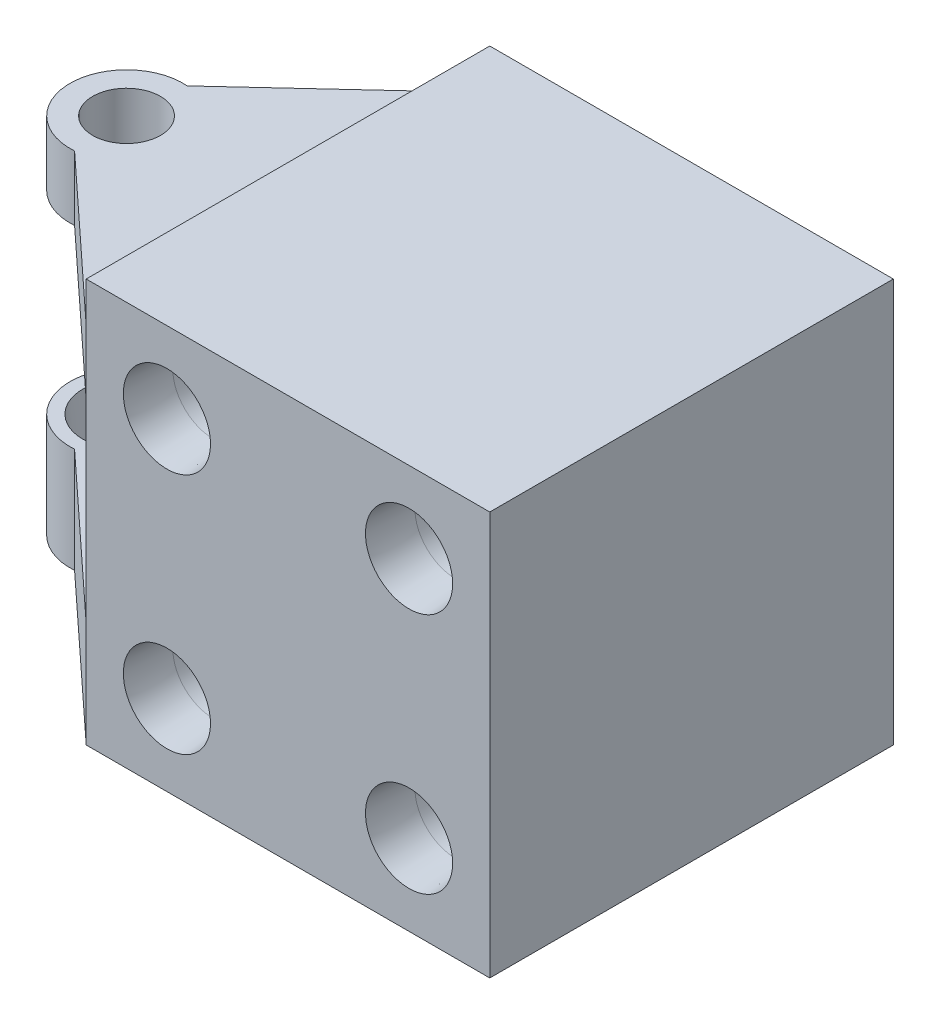
from build123d import *

# Parameters (mm, degrees)
SKETCH1_W                = 25
SKETCH1_H                = 25
BOSS_EXTRUDE1_DEPTH      = 12.5
BOSS_EXTRUDE1_DEPTH_BACK = 12.5
LPATTERN1_COUNT          = 2
LPATTERN1_PITCH          = 15
LPATTERN1_COUNT_DIR2     = 2
LPATTERN1_PITCH_DIR2     = 15
BOSS_EXTRUDE3_START      = 6
SKETCH4_R                = 2.1
BOSS_EXTRUDE3_DEPTH      = 4
BOSS_EXTRUDE5_START      = -6
SKETCH4_5_R              = 2.1
SKETCH4_5_R_2            = 3.5
BOSS_EXTRUDE5_DEPTH      = 6.5


with BuildPart() as part:
    # Sketch1 → Boss-Extrude1 (new, two sides)
    with BuildSketch(Plane.XY) as boss_extrude1_sk:
        Rectangle(SKETCH1_W, SKETCH1_H)
    extrude(amount=BOSS_EXTRUDE1_DEPTH)
    extrude(boss_extrude1_sk.sketch, amount=-BOSS_EXTRUDE1_DEPTH_BACK)

    # Sketch3 → CSK for M3 Oval Head Machine Screw1 (revolve, cut)
    with BuildSketch(Plane(origin=(-7.5, 7.5, 12.5), x_dir=(0, -1, 0), z_dir=(1, 0, 0))):
        Polygon((0, 0), (0, 11.502151548), (2.5, 10), (2.5, 2.860133251), (2.7, 0), align=None)
    csk_for_m3_oval_head_machine_screw1 = revolve(axis=Axis((-7.5, 7.5, 18.85), (0, 0, -1)), mode=Mode.SUBTRACT)

    # LPattern1: CSK for M3 Oval Head Machine Screw1 2 × 2
    with Locations(*[(j * LPATTERN1_PITCH_DIR2, -i * LPATTERN1_PITCH, 0) for i in range(LPATTERN1_COUNT) for j in range(LPATTERN1_COUNT_DIR2) if (i, j) != (0, 0)]):
        add(csk_for_m3_oval_head_machine_screw1, mode=Mode.SUBTRACT)

    # Sketch4 → Boss-Extrude3 (add)
    with BuildSketch(Plane(origin=(0, 0, 0), x_dir=(1, 0, 0), z_dir=(0, 1, 0)).offset(BOSS_EXTRUDE3_START)):
        with BuildLine():
            Line((-22.231166913, -3.489660266), (-12.5, -12.5))
            Line((-12.5, -12.5), (-12.5, 12.5))
            Line((-12.5, 12.5), (-22.231166913, 3.489660266))
            ThreePointArc((-22.231166913, 3.489660266), (-26, 0), (-22.231166913, -3.489660266))
        make_face()
        with Locations(Location((-22.5, 0, 0), (0, 0, 270))):
            Circle(SKETCH4_R, mode=Mode.SUBTRACT)
    extrude(amount=BOSS_EXTRUDE3_DEPTH)

    # Sketch4_5 → Boss-Extrude5 (add)
    with BuildSketch(Plane(origin=(0, 0, 0), x_dir=(1, 0, 0), z_dir=(0, 1, 0)).offset(BOSS_EXTRUDE5_START)):
        with BuildLine():
            ThreePointArc((-22.231166913, 3.489660266), (-24.87792811, 2.568162359), (-26, 0))
            Line((-26, 0), (-22.231166913, 3.489660266))
        make_face()
        with BuildLine():
            Line((-22.231166913, 3.489660266), (-26, 0))
            Line((-26, 0), (-22.231166913, -3.489660266))
            ThreePointArc((-22.231166913, -3.489660266), (-19.931837641, -2.37792811), (-19, 0))
            ThreePointArc((-19, 0), (-19.931837641, 2.37792811), (-22.231166913, 3.489660266))
        make_face()
        with Locations(Location((-22.5, 0, 0), (0, 0, 270))):
            Circle(SKETCH4_5_R, mode=Mode.SUBTRACT)
        with BuildLine():
            Line((-22.231166913, -3.489660266), (-26, 0))
            ThreePointArc((-26, 0), (-24.87792811, -2.568162359), (-22.231166913, -3.489660266))
        make_face()
        with Locations(Location((-22.5, 0, 0), (0, 0, 270))):
            Circle(SKETCH4_5_R)
        with Locations((-22.5, 0)):
            Circle(SKETCH4_5_R_2)
        Polygon((-26, 0), (-12.5, -12.5), (-12.5, 12.5), align=None)
    extrude(amount=-BOSS_EXTRUDE5_DEPTH)

    # Sketch8 → CSK for M3 Oval Head Machine Screw3 (revolve, cut)
    with BuildSketch(Plane(origin=(-22.5, -6, 0), x_dir=(0, 0, 1), z_dir=(1, 0, 0))):
        Polygon((0, 0), (0, 11.502151548), (2.5, 10), (2.5, 2.860133251), (2.7, 0), align=None)
    revolve(axis=Axis((-22.5, 0.35, 0), (0, -1, 0)), mode=Mode.SUBTRACT)


solid = part.part
